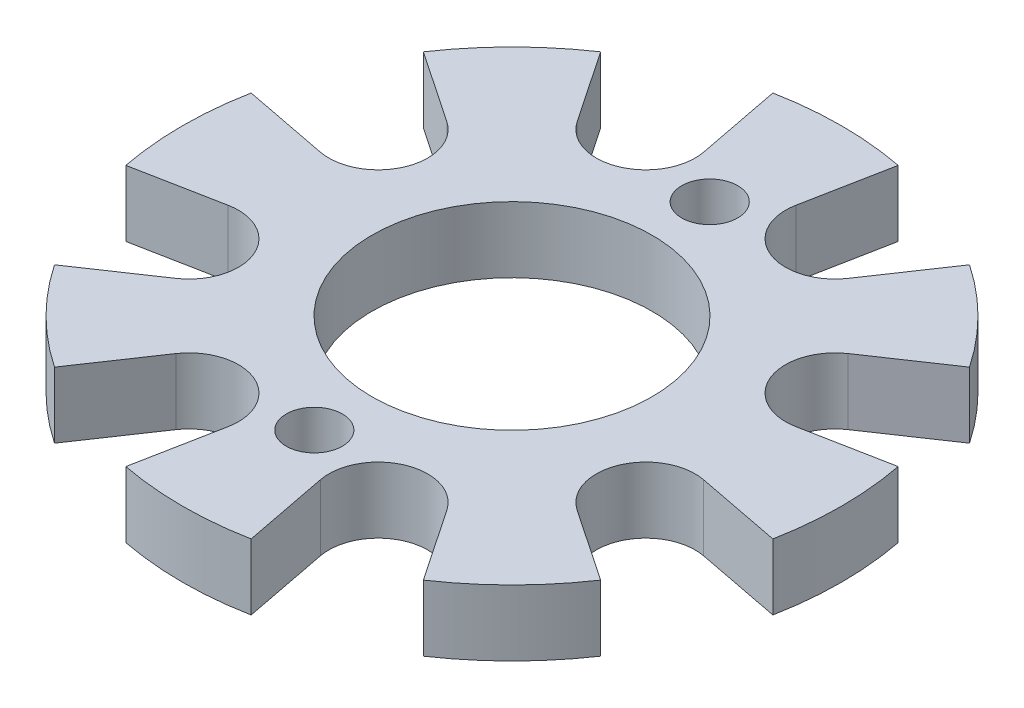
from build123d import *

# Parameters (mm, degrees)
SKETCH1_R           = 20
BOSS_EXTRUDE1_DEPTH = 4
CUT_EXTRUDE1_REACH  = 6
SKETCH2_R           = 4
SKETCH2_R_2         = 1.7
CUT_EXTRUDE3_DEPTH  = 4
CIRPATTERN1_COUNT   = 8
SKETCH4_R           = 8.5
CUT_EXTRUDE4_DEPTH  = 5


with BuildPart() as part:
    # Sketch1 → Boss-Extrude1 (new body)
    with BuildSketch(Plane(origin=(0, 0, 0), x_dir=(1, 0, 0), z_dir=(0, 1, 0))):
        Circle(SKETCH1_R)
    extrude(amount=BOSS_EXTRUDE1_DEPTH)

    # Sketch2 → Cut-Extrude1 (cut, up to next)
    with BuildSketch(Plane(origin=(0, 0, 0), x_dir=(1, 0, 0), z_dir=(0, 1, 0)), mode=Mode.PRIVATE) as cut_extrude1_sk1:
        Circle(SKETCH2_R)
    cut_extrude1_tool1 = extrude(cut_extrude1_sk1.sketch, amount=CUT_EXTRUDE1_REACH, mode=Mode.PRIVATE) & part.part
    add(cut_extrude1_tool1.solids().sort_by_distance((0, 0, 0))[0], mode=Mode.SUBTRACT)
    # Sketch2 → Cut-Extrude1 (cut, up to next)
    with BuildSketch(Plane(origin=(0, 0, 0), x_dir=(1, 0, 0), z_dir=(0, 1, 0)), mode=Mode.PRIVATE) as cut_extrude1_sk2:
        with Locations((0, 12)):
            Circle(SKETCH2_R_2)
    cut_extrude1_tool2 = extrude(cut_extrude1_sk2.sketch, amount=CUT_EXTRUDE1_REACH, mode=Mode.PRIVATE) & part.part
    add(cut_extrude1_tool2.solids().sort_by_distance((0, 0, -12))[0], mode=Mode.SUBTRACT)
    # Sketch2 → Cut-Extrude1 (cut, up to next)
    with BuildSketch(Plane(origin=(0, 0, 0), x_dir=(1, 0, 0), z_dir=(0, 1, 0)), mode=Mode.PRIVATE) as cut_extrude1_sk3:
        with Locations((0, -12)):
            Circle(SKETCH2_R_2)
    cut_extrude1_tool3 = extrude(cut_extrude1_sk3.sketch, amount=CUT_EXTRUDE1_REACH, mode=Mode.PRIVATE) & part.part
    add(cut_extrude1_tool3.solids().sort_by_distance((0, 0, 12))[0], mode=Mode.SUBTRACT)

    # Sketch3 → Cut-Extrude3 (cut)
    with BuildSketch(Plane(origin=(0, 0, 0), x_dir=(1, 0, 0), z_dir=(0, 1, 0))):
        with BuildLine():
            ThreePointArc((3.803515008, 19.635001237), (7.653668647, 18.47759065), (11.194551269, 16.573533778))
            Line((11.194551269, 16.573533778), (8.226281552, 12.179010297))
            ThreePointArc((8.226281552, 12.179010297), (4.592201188, 11.08655439), (2.7950013, 14.428720239))
            Line((2.7950013, 14.428720239), (3.803515008, 19.635001237))
        make_face()
    cut_extrude3 = extrude(amount=CUT_EXTRUDE3_DEPTH, mode=Mode.SUBTRACT)

    # CirPattern1: Cut-Extrude3 ×8 about axis
    cirpattern1_axis = Axis((0, 0, 0), (0, 1, 0))
    for i in range(1, CIRPATTERN1_COUNT):
        add(cut_extrude3.rotate(cirpattern1_axis, i * 360 / CIRPATTERN1_COUNT), mode=Mode.SUBTRACT)

    # Sketch4 → Cut-Extrude4 (cut, through all)
    with BuildSketch(Plane(origin=(0, 4, 0), x_dir=(1, 0, 0), z_dir=(0, 1, 0))):
        Circle(SKETCH4_R)
    extrude(amount=-CUT_EXTRUDE4_DEPTH, mode=Mode.SUBTRACT)


solid = part.part
